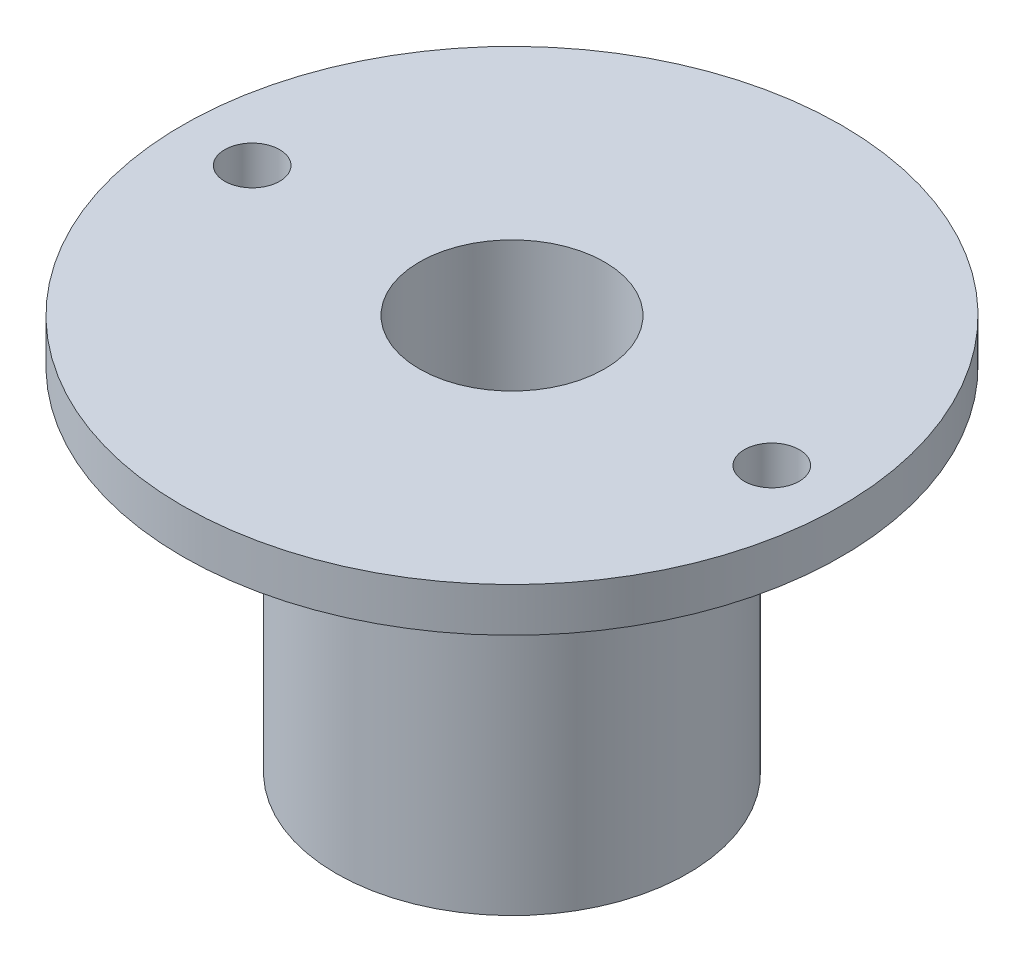
from build123d import *

# Parameters (mm, degrees)
SKETCH1_R                   = 15
BOSS_EXTRUDE1_DEPTH         = 2
SKETCH2_R                   = 8
BOSS_EXTRUDE2_DEPTH         = 16
F_3_8_24_TAPPED_HOLE1_D     = 8.4328
F_3_8_24_TAPPED_HOLE1_DEPTH = 24.4
F_3_8_24_TAPPED_HOLE1_TIP   = 2.533468714
SKETCH5_R                   = 1.25
CUT_EXTRUDE1_DEPTH          = 10


with BuildPart() as part:
    # Sketch1 → Boss-Extrude1 (new body)
    with BuildSketch(Plane(origin=(0, 0, 0), x_dir=(1, 0, 0), z_dir=(0, 1, 0))):
        Circle(SKETCH1_R)
    extrude(amount=-BOSS_EXTRUDE1_DEPTH)

    # Sketch2 → Boss-Extrude2 (add)
    with BuildSketch(Plane.XZ.offset(2)):
        Circle(SKETCH2_R)
    extrude(amount=BOSS_EXTRUDE2_DEPTH)

    # 3/8-24 Tapped Hole1
    with Locations(Plane(origin=(0, -18, 0), x_dir=(-1, 0, 0), z_dir=(0, -1, 0))):
        with Locations((0, 0)):
            Hole(F_3_8_24_TAPPED_HOLE1_D / 2, depth=F_3_8_24_TAPPED_HOLE1_DEPTH)
            with Locations((0, 0, -(F_3_8_24_TAPPED_HOLE1_DEPTH + F_3_8_24_TAPPED_HOLE1_TIP / 2))):  # 118° drill point
                Cone(0, F_3_8_24_TAPPED_HOLE1_D / 2, F_3_8_24_TAPPED_HOLE1_TIP, mode=Mode.SUBTRACT)

    # Sketch5 → Cut-Extrude1 (cut)
    with BuildSketch(Plane(origin=(0, 0, 0), x_dir=(1, 0, 0), z_dir=(0, 1, 0))):
        with Locations((11.825, 0)):
            Circle(SKETCH5_R)
        with Locations((-11.825, 0)):
            Circle(SKETCH5_R)
    extrude(amount=-CUT_EXTRUDE1_DEPTH, mode=Mode.SUBTRACT)


solid = part.part
